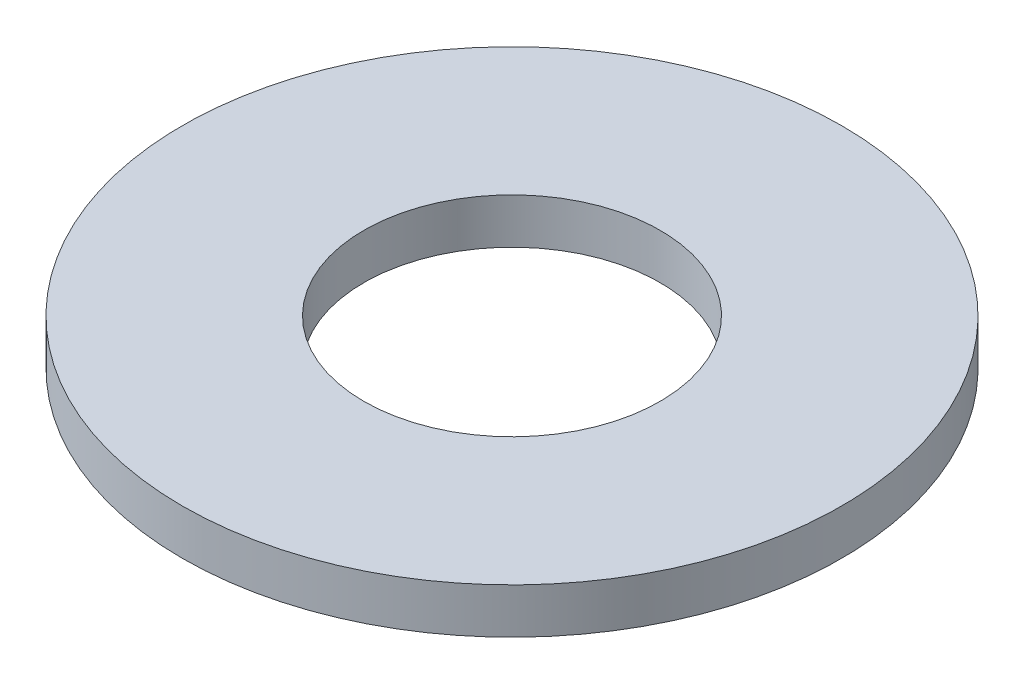
from build123d import *

# Parameters (mm, degrees)
SKETCH1_R           = 7.9375
BOSS_EXTRUDE1_DEPTH = 1.0922
SKETCH5_R           = 3.5687
CUT_EXTRUDE1_DEPTH  = 2.0922


with BuildPart() as part:
    # Sketch1 → Boss-Extrude1 (new body)
    with BuildSketch(Plane(origin=(0, 0, 0), x_dir=(1, 0, 0), z_dir=(0, 1, 0))):
        Circle(SKETCH1_R)
    extrude(amount=BOSS_EXTRUDE1_DEPTH)

    # Sketch5 → Cut-Extrude1 (cut, through all)
    with BuildSketch(Plane(origin=(0, 1.0922, 0), x_dir=(-1, 0, 0), z_dir=(0, 1, 0))):
        Circle(SKETCH5_R)
    extrude(amount=-CUT_EXTRUDE1_DEPTH, mode=Mode.SUBTRACT)


solid = part.part
